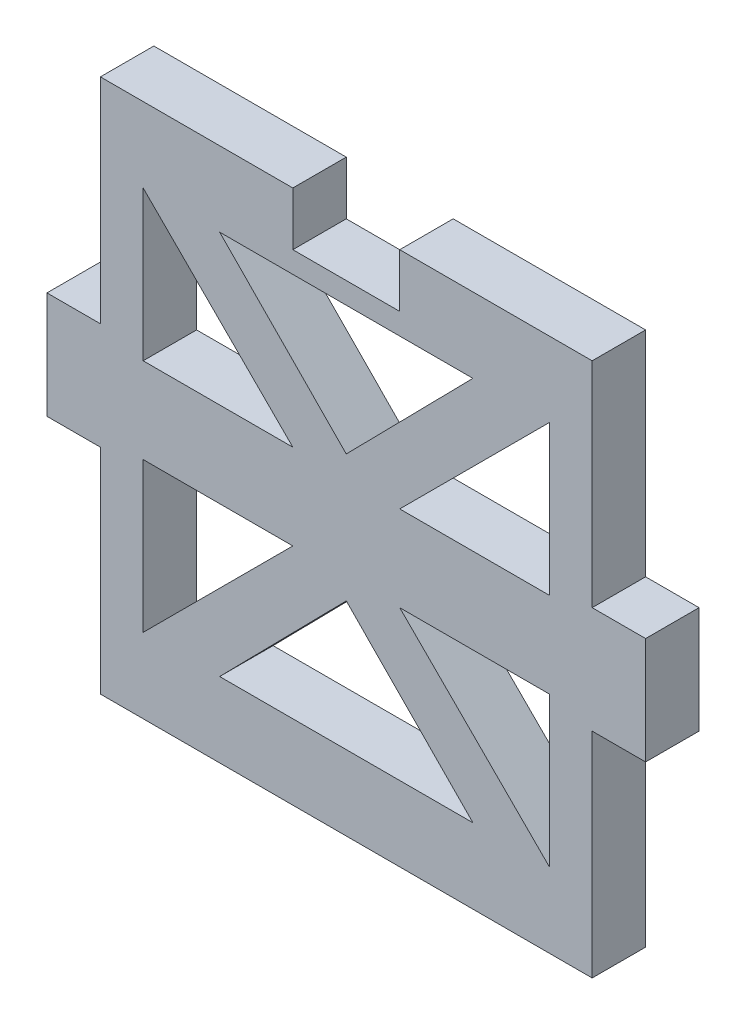
from build123d import *

# Parameters (mm, degrees)
EXTRUDE1_DEPTH     = 3.175
CUT_EXTRUDE1_REACH = 5.175


with BuildPart() as part:
    # Sketch1 → Extrude1 (new body)
    with BuildSketch(Plane.XY):
        Polygon((-14.605, 15.875), (-3.175, 15.875), (-3.175, 12.7), (3.175, 12.7), (3.175, 15.875), (14.605, 15.875), (14.605, 3.175), (17.78, 3.175), (17.78, -3.175), (14.605, -3.175), (14.605, -15.875), (3.175, -15.875), (-3.175, -15.875), (-14.605, -15.875), (-14.605, -3.175), (-17.78, -3.175), (-17.78, 3.175), (-14.605, 3.175), align=None)
    extrude(amount=EXTRUDE1_DEPTH)

    # Sketch2 → Cut-Extrude1 (cut, up to next)
    with BuildSketch(Plane.XY.offset(3.175), mode=Mode.PRIVATE) as cut_extrude1_sk1:
        Polygon((3.175, 2.54), (12.065, 11.43), (12.065, 2.54), align=None)
    cut_extrude1_tool1 = extrude(cut_extrude1_sk1.sketch, amount=-CUT_EXTRUDE1_REACH, mode=Mode.PRIVATE) & part.part
    add(cut_extrude1_tool1.solids().sort_by_distance((9.101667, 5.503333, 3.175))[0], mode=Mode.SUBTRACT)
    # Sketch2 → Cut-Extrude1 (cut, up to next)
    with BuildSketch(Plane.XY.offset(3.175), mode=Mode.PRIVATE) as cut_extrude1_sk2:
        Polygon((-12.065, 2.54), (-3.175, 2.54), (-12.065, 11.43), align=None)
    cut_extrude1_tool2 = extrude(cut_extrude1_sk2.sketch, amount=-CUT_EXTRUDE1_REACH, mode=Mode.PRIVATE) & part.part
    add(cut_extrude1_tool2.solids().sort_by_distance((-9.101667, 5.503333, 3.175))[0], mode=Mode.SUBTRACT)
    # Sketch2 → Cut-Extrude1 (cut, up to next)
    with BuildSketch(Plane.XY.offset(3.175), mode=Mode.PRIVATE) as cut_extrude1_sk3:
        Polygon((-3.175, -2.54), (-12.065, -11.43), (-12.065, -2.54), align=None)
    cut_extrude1_tool3 = extrude(cut_extrude1_sk3.sketch, amount=-CUT_EXTRUDE1_REACH, mode=Mode.PRIVATE) & part.part
    add(cut_extrude1_tool3.solids().sort_by_distance((-9.101667, -5.503333, 3.175))[0], mode=Mode.SUBTRACT)
    # Sketch2 → Cut-Extrude1 (cut, up to next)
    with BuildSketch(Plane.XY.offset(3.175), mode=Mode.PRIVATE) as cut_extrude1_sk4:
        Polygon((12.065, -2.54), (3.175, -2.54), (12.065, -11.43), align=None)
    cut_extrude1_tool4 = extrude(cut_extrude1_sk4.sketch, amount=-CUT_EXTRUDE1_REACH, mode=Mode.PRIVATE) & part.part
    add(cut_extrude1_tool4.solids().sort_by_distance((9.101667, -5.503333, 3.175))[0], mode=Mode.SUBTRACT)
    # Sketch2 → Cut-Extrude1 (cut, up to next)
    with BuildSketch(Plane.XY.offset(3.175), mode=Mode.PRIVATE) as cut_extrude1_sk5:
        Polygon((-7.522107489, 11.43), (7.522107489, 11.43), (0, 3.778290122), align=None)
    cut_extrude1_tool5 = extrude(cut_extrude1_sk5.sketch, amount=-CUT_EXTRUDE1_REACH, mode=Mode.PRIVATE) & part.part
    add(cut_extrude1_tool5.solids().sort_by_distance((0, 8.87943, 3.175))[0], mode=Mode.SUBTRACT)
    # Sketch2 → Cut-Extrude1 (cut, up to next)
    with BuildSketch(Plane.XY.offset(3.175), mode=Mode.PRIVATE) as cut_extrude1_sk6:
        Polygon((0, -3.778290122), (7.522107489, -11.43), (-7.522107489, -11.43), align=None)
    cut_extrude1_tool6 = extrude(cut_extrude1_sk6.sketch, amount=-CUT_EXTRUDE1_REACH, mode=Mode.PRIVATE) & part.part
    add(cut_extrude1_tool6.solids().sort_by_distance((0, -8.87943, 3.175))[0], mode=Mode.SUBTRACT)


solid = part.part
